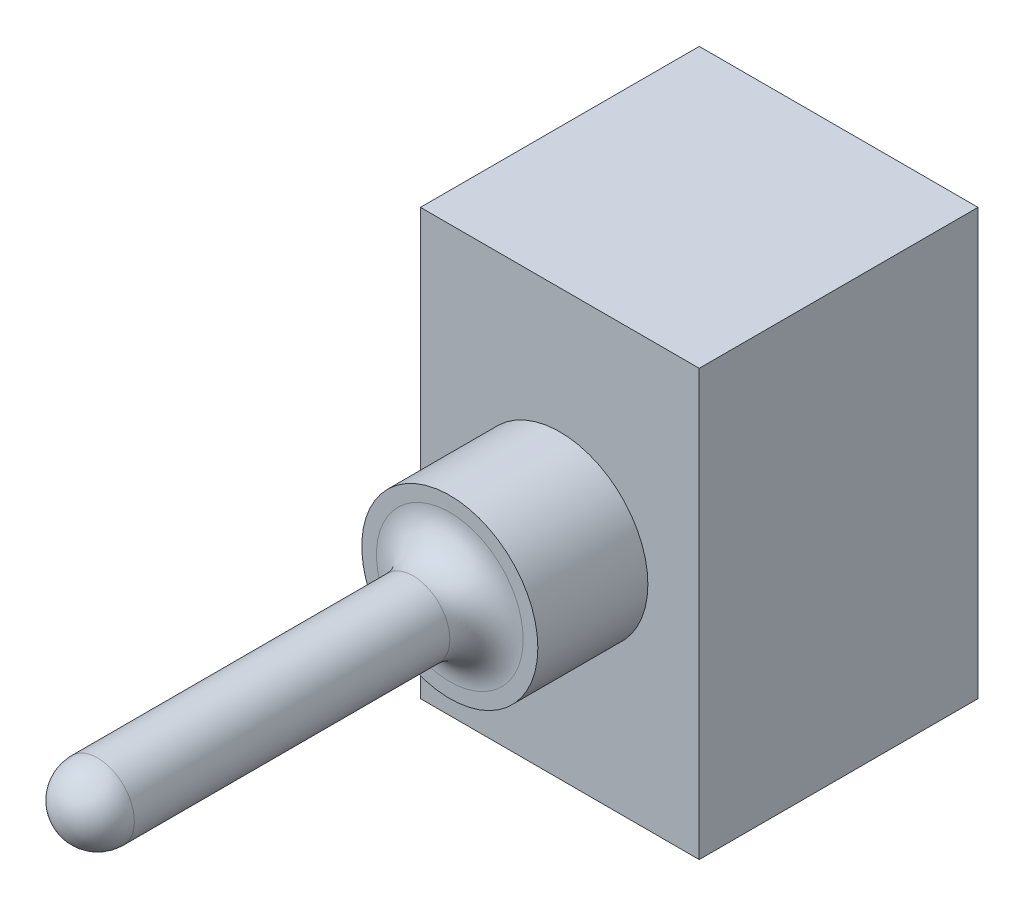
from build123d import *

# Parameters (mm, degrees)
ESQUISSE1_W        = 19
ESQUISSE1_H        = 29
BOSS_EXTRU_1_DEPTH = 19
ESQUISSE3_R        = 6
BOSS_EXTRU_2_DEPTH = 7.5
ESQUISSE4_R        = 2.5
BOSS_EXTRU_3_DEPTH = 26.5
CONG_3_R           = 2.5


with BuildPart() as part:
    # Esquisse1 → Boss.-Extru.1 (new body)
    with BuildSketch(Plane.XY):
        with Locations((-54.306805708, 14.681818182)):
            Rectangle(ESQUISSE1_W, ESQUISSE1_H)
    extrude(amount=BOSS_EXTRU_1_DEPTH)

    # Esquisse3 → Boss.-Extru.2 (add)
    with BuildSketch(Plane.XY.offset(19)):
        with Locations((-54.306805708, 14.681818182)):
            Circle(ESQUISSE3_R)
    extrude(amount=BOSS_EXTRU_2_DEPTH)

    # Esquisse4 → Boss.-Extru.3 (add)
    with BuildSketch(Plane.XY.offset(26.5)):
        with Locations((-54.306805708, 14.681818182)):
            Circle(ESQUISSE4_R)
    extrude(amount=BOSS_EXTRU_3_DEPTH)

    # Congé3
    cong_3_edges = [part.edges().sort_by_distance(p)[0] for p in [
        (-56.806805708, 14.681818182, 26.5),
        (-56.806805708, 14.681818182, 53),
    ]]
    fillet(cong_3_edges, radius=CONG_3_R)


solid = part.part
